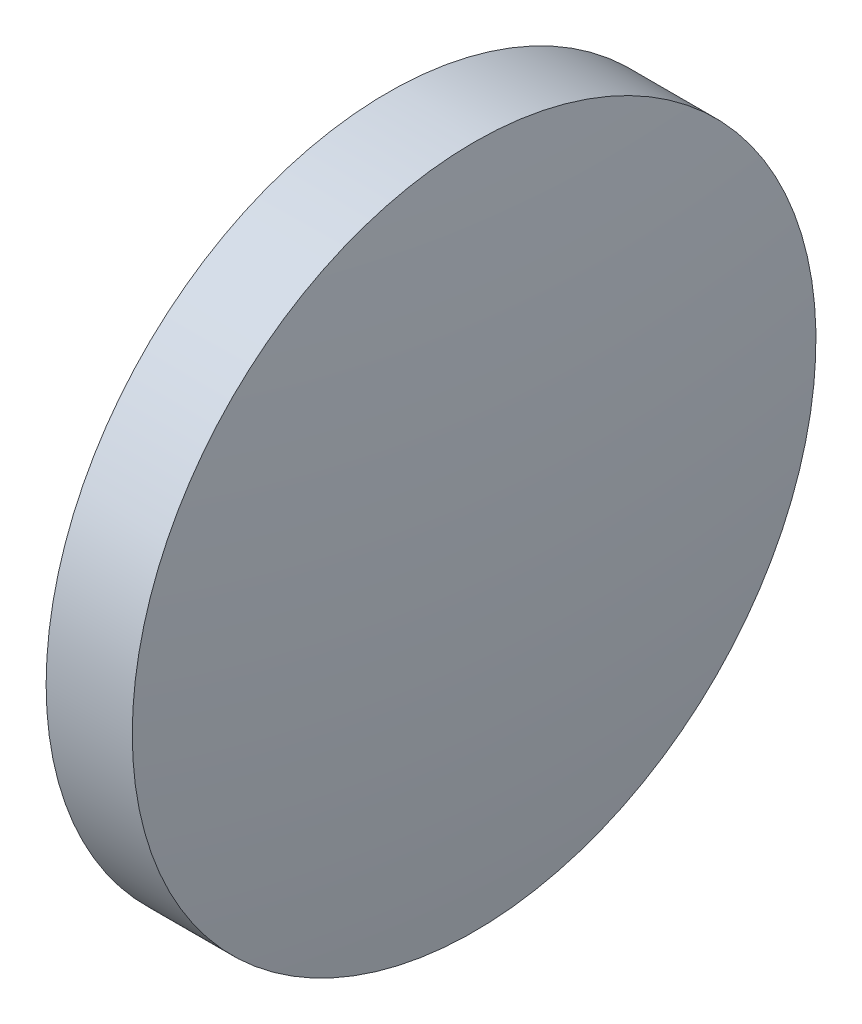
from build123d import *


with BuildPart() as part:
    # 草图1 → 旋转1 (revolve)
    with BuildSketch(Plane.XY):
        with BuildLine():
            Line((479.420489015, 287.478678898), (479.420489015, 300.178678898))
            Line((479.420489015, 300.178678898), (482.620489015, 300.178678898))
            ThreePointArc((482.620489015, 300.178678898), (483.220291008, 293.84126485), (483.420489015, 287.478678898))
            Line((483.420489015, 287.478678898), (479.420489015, 287.478678898))
        make_face()
    revolve(axis=Axis((473.68227098, 287.478678898, 0), (1, 0, 0)))


solid = part.part
